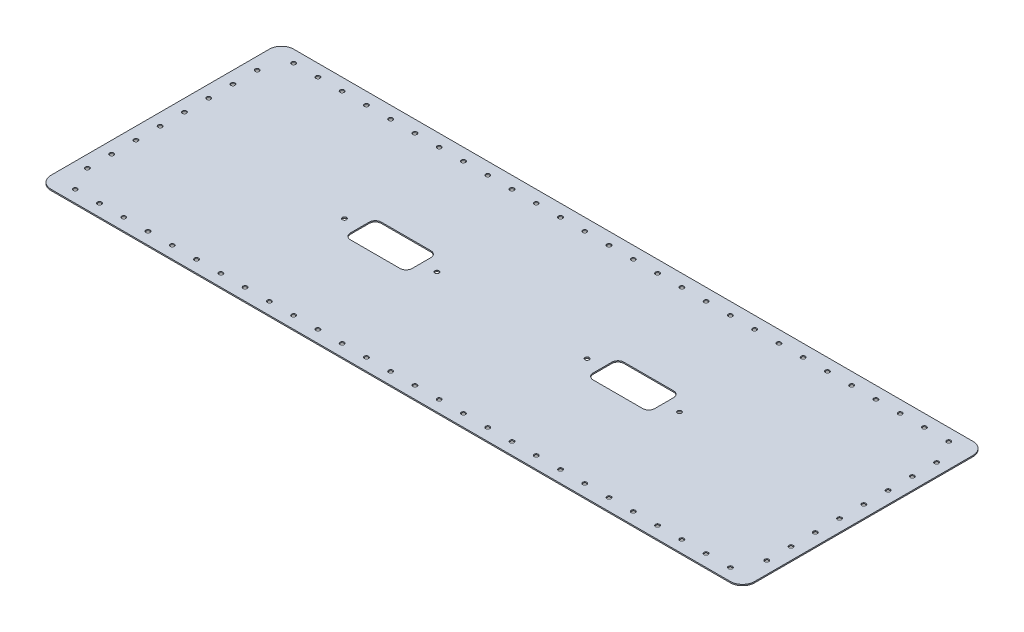
from build123d import *

# Parameters (mm, degrees)
SKETCH1_W                      = 580
SKETCH1_H                      = 200
BOSS_EXTRUDE1_DEPTH            = 1
FILLET1_R                      = 10
M3_CLEARANCE_HOLE1_AT_2_COUNT  = 2
M3_CLEARANCE_HOLE1_AT_2_PITCH  = 22.360679775
M3_CLEARANCE_HOLE1_AT_3_COUNT  = 2
M3_CLEARANCE_HOLE1_AT_3_PITCH  = 36.055512755
M3_CLEARANCE_HOLE1_AT_4_COUNT  = 2
M3_CLEARANCE_HOLE1_AT_4_PITCH  = 53.851648071
M3_CLEARANCE_HOLE1_AT_5_COUNT  = 2
M3_CLEARANCE_HOLE1_AT_5_PITCH  = 72.801098893
M3_CLEARANCE_HOLE1_AT_6_COUNT  = 2
M3_CLEARANCE_HOLE1_AT_6_PITCH  = 92.195444573
M3_CLEARANCE_HOLE1_AT_7_COUNT  = 2
M3_CLEARANCE_HOLE1_AT_7_PITCH  = 111.803398875
M3_CLEARANCE_HOLE1_AT_8_COUNT  = 2
M3_CLEARANCE_HOLE1_AT_8_PITCH  = 131.52946438
M3_CLEARANCE_HOLE1_AT_9_COUNT  = 2
M3_CLEARANCE_HOLE1_AT_9_PITCH  = 151.327459504
M3_CLEARANCE_HOLE1_AT_10_COUNT = 2
M3_CLEARANCE_HOLE1_AT_10_PITCH = 171.172427686
M3_CLEARANCE_HOLE1_AT_11_COUNT = 2
M3_CLEARANCE_HOLE1_AT_11_PITCH = 191.049731745
M3_CLEARANCE_HOLE1_AT_12_COUNT = 2
M3_CLEARANCE_HOLE1_AT_12_PITCH = 210.950231097
M3_CLEARANCE_HOLE1_AT_13_COUNT = 2
M3_CLEARANCE_HOLE1_AT_13_PITCH = 230.867927612
M3_CLEARANCE_HOLE1_AT_14_COUNT = 2
M3_CLEARANCE_HOLE1_AT_14_PITCH = 250.79872408
M3_CLEARANCE_HOLE1_AT_15_COUNT = 2
M3_CLEARANCE_HOLE1_AT_15_PITCH = 270.739727414
M3_CLEARANCE_HOLE1_AT_16_COUNT = 2
M3_CLEARANCE_HOLE1_AT_16_PITCH = 290.688837075
M3_CLEARANCE_HOLE1_AT_17_COUNT = 2
M3_CLEARANCE_HOLE1_AT_17_PITCH = 310.64449134
M3_CLEARANCE_HOLE1_AT_18_COUNT = 2
M3_CLEARANCE_HOLE1_AT_18_PITCH = 330.605505096
M3_CLEARANCE_HOLE1_AT_19_COUNT = 2
M3_CLEARANCE_HOLE1_AT_19_PITCH = 350.570962859
M3_CLEARANCE_HOLE1_AT_20_COUNT = 2
M3_CLEARANCE_HOLE1_AT_20_PITCH = 370.540146273
M3_CLEARANCE_HOLE1_AT_21_COUNT = 2
M3_CLEARANCE_HOLE1_AT_21_PITCH = 390.512483795
M3_CLEARANCE_HOLE1_AT_22_COUNT = 2
M3_CLEARANCE_HOLE1_AT_22_PITCH = 410.487515035
M3_CLEARANCE_HOLE1_AT_23_COUNT = 2
M3_CLEARANCE_HOLE1_AT_23_PITCH = 430.464865001
M3_CLEARANCE_HOLE1_AT_24_COUNT = 2
M3_CLEARANCE_HOLE1_AT_24_PITCH = 450.444225182
M3_CLEARANCE_HOLE1_AT_25_COUNT = 2
M3_CLEARANCE_HOLE1_AT_25_PITCH = 470.425339454
M3_CLEARANCE_HOLE1_AT_26_COUNT = 2
M3_CLEARANCE_HOLE1_AT_26_PITCH = 490.40799341
M3_CLEARANCE_HOLE1_AT_27_COUNT = 2
M3_CLEARANCE_HOLE1_AT_27_PITCH = 510.392006207
M3_CLEARANCE_HOLE1_AT_28_COUNT = 2
M3_CLEARANCE_HOLE1_AT_28_PITCH = 530.377224247
M3_CLEARANCE_HOLE1_AT_29_COUNT = 2
M3_CLEARANCE_HOLE1_AT_29_PITCH = 550.363516233
M3_CLEARANCE_HOLE1_AT_30_COUNT = 2
M3_CLEARANCE_HOLE1_AT_30_PITCH = 19.996953903
M3_CLEARANCE_HOLE1_AT_31_COUNT = 2
M3_CLEARANCE_HOLE1_AT_31_PITCH = 39.993907806
M3_CLEARANCE_HOLE1_AT_32_COUNT = 2
M3_CLEARANCE_HOLE1_AT_32_PITCH = 59.990861709
M3_CLEARANCE_HOLE1_AT_33_COUNT = 2
M3_CLEARANCE_HOLE1_AT_33_PITCH = 79.987815613
M3_CLEARANCE_HOLE1_AT_34_COUNT = 2
M3_CLEARANCE_HOLE1_AT_34_PITCH = 99.984769516
M3_CLEARANCE_HOLE1_AT_35_COUNT = 2
M3_CLEARANCE_HOLE1_AT_35_PITCH = 119.981723419
M3_CLEARANCE_HOLE1_AT_36_COUNT = 2
M3_CLEARANCE_HOLE1_AT_36_PITCH = 139.978677322
M3_CLEARANCE_HOLE1_AT_37_COUNT = 2
M3_CLEARANCE_HOLE1_AT_37_PITCH = 160.312195419
M3_CLEARANCE_HOLE1_AT_38_COUNT = 2
M3_CLEARANCE_HOLE1_AT_38_PITCH = 162.788205961
M3_CLEARANCE_HOLE1_AT_39_COUNT = 2
M3_CLEARANCE_HOLE1_AT_39_PITCH = 167.630546142
M3_CLEARANCE_HOLE1_AT_40_COUNT = 2
M3_CLEARANCE_HOLE1_AT_40_PITCH = 174.642491966
M3_CLEARANCE_HOLE1_AT_41_COUNT = 2
M3_CLEARANCE_HOLE1_AT_41_PITCH = 183.575597507
M3_CLEARANCE_HOLE1_AT_42_COUNT = 2
M3_CLEARANCE_HOLE1_AT_42_PITCH = 194.164878389
M3_CLEARANCE_HOLE1_AT_43_COUNT = 2
M3_CLEARANCE_HOLE1_AT_43_PITCH = 206.155281281
M3_CLEARANCE_HOLE1_AT_44_COUNT = 2
M3_CLEARANCE_HOLE1_AT_44_PITCH = 219.317121995
M3_CLEARANCE_HOLE1_AT_45_COUNT = 2
M3_CLEARANCE_HOLE1_AT_45_PITCH = 233.452350599
M3_CLEARANCE_HOLE1_AT_46_COUNT = 2
M3_CLEARANCE_HOLE1_AT_46_PITCH = 248.394846967
M3_CLEARANCE_HOLE1_AT_47_COUNT = 2
M3_CLEARANCE_HOLE1_AT_47_PITCH = 264.007575649
M3_CLEARANCE_HOLE1_AT_48_COUNT = 2
M3_CLEARANCE_HOLE1_AT_48_PITCH = 280.178514522
M3_CLEARANCE_HOLE1_AT_49_COUNT = 2
M3_CLEARANCE_HOLE1_AT_49_PITCH = 296.816441593
M3_CLEARANCE_HOLE1_AT_50_COUNT = 2
M3_CLEARANCE_HOLE1_AT_50_PITCH = 313.84709653
M3_CLEARANCE_HOLE1_AT_51_COUNT = 2
M3_CLEARANCE_HOLE1_AT_51_PITCH = 331.209903234
M3_CLEARANCE_HOLE1_AT_52_COUNT = 2
M3_CLEARANCE_HOLE1_AT_52_PITCH = 348.85527085
M3_CLEARANCE_HOLE1_AT_53_COUNT = 2
M3_CLEARANCE_HOLE1_AT_53_PITCH = 366.742416418
M3_CLEARANCE_HOLE1_AT_54_COUNT = 2
M3_CLEARANCE_HOLE1_AT_54_PITCH = 384.837628098
M3_CLEARANCE_HOLE1_AT_55_COUNT = 2
M3_CLEARANCE_HOLE1_AT_55_PITCH = 403.112887415
M3_CLEARANCE_HOLE1_AT_56_COUNT = 2
M3_CLEARANCE_HOLE1_AT_56_PITCH = 421.544778167
M3_CLEARANCE_HOLE1_AT_57_COUNT = 2
M3_CLEARANCE_HOLE1_AT_57_PITCH = 440.113621693
M3_CLEARANCE_HOLE1_AT_58_COUNT = 2
M3_CLEARANCE_HOLE1_AT_58_PITCH = 458.802789878
M3_CLEARANCE_HOLE1_AT_59_COUNT = 2
M3_CLEARANCE_HOLE1_AT_59_PITCH = 477.59815745
M3_CLEARANCE_HOLE1_AT_60_COUNT = 2
M3_CLEARANCE_HOLE1_AT_60_PITCH = 496.487663492
M3_CLEARANCE_HOLE1_AT_61_COUNT = 2
M3_CLEARANCE_HOLE1_AT_61_PITCH = 515.460958754
M3_CLEARANCE_HOLE1_AT_62_COUNT = 2
M3_CLEARANCE_HOLE1_AT_62_PITCH = 534.509120596
M3_CLEARANCE_HOLE1_AT_63_COUNT = 2
M3_CLEARANCE_HOLE1_AT_63_PITCH = 553.624421427
M3_CLEARANCE_HOLE1_AT_64_COUNT = 2
M3_CLEARANCE_HOLE1_AT_64_PITCH = 572.800139665
M3_CLEARANCE_HOLE1_AT_65_COUNT = 2
M3_CLEARANCE_HOLE1_AT_65_PITCH = 560
M3_CLEARANCE_HOLE1_AT_66_COUNT = 2
M3_CLEARANCE_HOLE1_AT_66_PITCH = 560.356920333
M3_CLEARANCE_HOLE1_AT_67_COUNT = 2
M3_CLEARANCE_HOLE1_AT_67_PITCH = 561.426319887
M3_CLEARANCE_HOLE1_AT_68_COUNT = 2
M3_CLEARANCE_HOLE1_AT_68_PITCH = 563.204140156
M3_CLEARANCE_HOLE1_AT_69_COUNT = 2
M3_CLEARANCE_HOLE1_AT_69_PITCH = 565.683701945
M3_CLEARANCE_HOLE1_AT_70_COUNT = 2
M3_CLEARANCE_HOLE1_AT_70_PITCH = 568.855828954
M3_CLEARANCE_HOLE1_AT_71_COUNT = 2
M3_CLEARANCE_HOLE1_AT_71_PITCH = 572.709013334
M3_CLEARANCE_HOLE1_AT_72_COUNT = 2
M3_CLEARANCE_HOLE1_AT_72_PITCH = 577.229616448
SKETCH4_W                      = 50.8
SKETCH4_H                      = 25.4
CUT_EXTRUDE1_DEPTH             = 10
FILLET2_R                      = 5
M3_CLEARANCE_HOLE4_AT_2_COUNT  = 2
M3_CLEARANCE_HOLE4_AT_2_PITCH  = 76.2
M3_CLEARANCE_HOLE4_AT_3_COUNT  = 2
M3_CLEARANCE_HOLE4_AT_3_PITCH  = 123.8
M3_CLEARANCE_HOLE4_AT_4_COUNT  = 2
M3_CLEARANCE_HOLE4_AT_4_PITCH  = 200


with BuildPart() as part:
    # Sketch1 → Boss-Extrude1 (new body)
    with BuildSketch(Plane(origin=(0, 0, 0), x_dir=(1, 0, 0), z_dir=(0, 1, 0))):
        Rectangle(SKETCH1_W, SKETCH1_H)
    extrude(amount=BOSS_EXTRUDE1_DEPTH)

    # Fillet1
    fillet1_edges = [part.edges().sort_by_distance(p)[0] for p in [
        (290, 0.5, 100),
        (-290, 0.5, 100),
        (-290, 0.5, -100),
        (290, 0.5, -100),
    ]]
    fillet(fillet1_edges, radius=FILLET1_R)

    # Sketch3 → M3 Clearance Hole1 (revolve, cut)
    with BuildSketch(Plane(origin=(280, 1, -70), x_dir=(0, 0, 1), z_dir=(1, 0, 0))):
        Polygon((0, 0), (0, 1), (1.7, 1), (1.7, 0.025), (1.725, 0), align=None)
    m3_clearance_hole1 = revolve(axis=Axis((280, 7.35, -70), (0, -1, 0)), mode=Mode.SUBTRACT)

    # M3 Clearance Hole1 at 2: M3 Clearance Hole1 ×2
    with Locations(*[Vector(-0.447213595, 0, -0.894427191) * (i * M3_CLEARANCE_HOLE1_AT_2_PITCH) for i in range(1, M3_CLEARANCE_HOLE1_AT_2_COUNT)]):
        add(m3_clearance_hole1, mode=Mode.SUBTRACT)

    # M3 Clearance Hole1 at 3: M3 Clearance Hole1 ×2
    with Locations(*[Vector(-0.832050294, 0, -0.554700196) * (i * M3_CLEARANCE_HOLE1_AT_3_PITCH) for i in range(1, M3_CLEARANCE_HOLE1_AT_3_COUNT)]):
        add(m3_clearance_hole1, mode=Mode.SUBTRACT)

    # M3 Clearance Hole1 at 4: M3 Clearance Hole1 ×2
    with Locations(*[Vector(-0.928476691, 0, -0.371390676) * (i * M3_CLEARANCE_HOLE1_AT_4_PITCH) for i in range(1, M3_CLEARANCE_HOLE1_AT_4_COUNT)]):
        add(m3_clearance_hole1, mode=Mode.SUBTRACT)

    # M3 Clearance Hole1 at 5: M3 Clearance Hole1 ×2
    with Locations(*[Vector(-0.961523948, 0, -0.274721128) * (i * M3_CLEARANCE_HOLE1_AT_5_PITCH) for i in range(1, M3_CLEARANCE_HOLE1_AT_5_COUNT)]):
        add(m3_clearance_hole1, mode=Mode.SUBTRACT)

    # M3 Clearance Hole1 at 6: M3 Clearance Hole1 ×2
    with Locations(*[Vector(-0.97618706, 0, -0.216930458) * (i * M3_CLEARANCE_HOLE1_AT_6_PITCH) for i in range(1, M3_CLEARANCE_HOLE1_AT_6_COUNT)]):
        add(m3_clearance_hole1, mode=Mode.SUBTRACT)

    # M3 Clearance Hole1 at 7: M3 Clearance Hole1 ×2
    with Locations(*[Vector(-0.98386991, 0, -0.178885438) * (i * M3_CLEARANCE_HOLE1_AT_7_PITCH) for i in range(1, M3_CLEARANCE_HOLE1_AT_7_COUNT)]):
        add(m3_clearance_hole1, mode=Mode.SUBTRACT)

    # M3 Clearance Hole1 at 8: M3 Clearance Hole1 ×2
    with Locations(*[Vector(-0.988371698, 0, -0.152057184) * (i * M3_CLEARANCE_HOLE1_AT_8_PITCH) for i in range(1, M3_CLEARANCE_HOLE1_AT_8_COUNT)]):
        add(m3_clearance_hole1, mode=Mode.SUBTRACT)

    # M3 Clearance Hole1 at 9: M3 Clearance Hole1 ×2
    with Locations(*[Vector(-0.991227901, 0, -0.13216372) * (i * M3_CLEARANCE_HOLE1_AT_9_PITCH) for i in range(1, M3_CLEARANCE_HOLE1_AT_9_COUNT)]):
        add(m3_clearance_hole1, mode=Mode.SUBTRACT)

    # M3 Clearance Hole1 at 10: M3 Clearance Hole1 ×2
    with Locations(*[Vector(-0.993150604, 0, -0.116841248) * (i * M3_CLEARANCE_HOLE1_AT_10_PITCH) for i in range(1, M3_CLEARANCE_HOLE1_AT_10_COUNT)]):
        add(m3_clearance_hole1, mode=Mode.SUBTRACT)

    # M3 Clearance Hole1 at 11: M3 Clearance Hole1 ×2
    with Locations(*[Vector(-0.994505453, 0, -0.104684785) * (i * M3_CLEARANCE_HOLE1_AT_11_PITCH) for i in range(1, M3_CLEARANCE_HOLE1_AT_11_COUNT)]):
        add(m3_clearance_hole1, mode=Mode.SUBTRACT)

    # M3 Clearance Hole1 at 12: M3 Clearance Hole1 ×2
    with Locations(*[Vector(-0.995495473, 0, -0.094809093) * (i * M3_CLEARANCE_HOLE1_AT_12_PITCH) for i in range(1, M3_CLEARANCE_HOLE1_AT_12_COUNT)]):
        add(m3_clearance_hole1, mode=Mode.SUBTRACT)

    # M3 Clearance Hole1 at 13: M3 Clearance Hole1 ×2
    with Locations(*[Vector(-0.996240588, 0, -0.086629616) * (i * M3_CLEARANCE_HOLE1_AT_13_PITCH) for i in range(1, M3_CLEARANCE_HOLE1_AT_13_COUNT)]):
        add(m3_clearance_hole1, mode=Mode.SUBTRACT)

    # M3 Clearance Hole1 at 14: M3 Clearance Hole1 ×2
    with Locations(*[Vector(-0.996815279, 0, -0.079745222) * (i * M3_CLEARANCE_HOLE1_AT_14_PITCH) for i in range(1, M3_CLEARANCE_HOLE1_AT_14_COUNT)]):
        add(m3_clearance_hole1, mode=Mode.SUBTRACT)

    # M3 Clearance Hole1 at 15: M3 Clearance Hole1 ×2
    with Locations(*[Vector(-0.997267754, 0, -0.073871686) * (i * M3_CLEARANCE_HOLE1_AT_15_PITCH) for i in range(1, M3_CLEARANCE_HOLE1_AT_15_COUNT)]):
        add(m3_clearance_hole1, mode=Mode.SUBTRACT)

    # M3 Clearance Hole1 at 16: M3 Clearance Hole1 ×2
    with Locations(*[Vector(-0.997630328, 0, -0.068802092) * (i * M3_CLEARANCE_HOLE1_AT_16_PITCH) for i in range(1, M3_CLEARANCE_HOLE1_AT_16_COUNT)]):
        add(m3_clearance_hole1, mode=Mode.SUBTRACT)

    # M3 Clearance Hole1 at 17: M3 Clearance Hole1 ×2
    with Locations(*[Vector(-0.997925309, 0, -0.064382278) * (i * M3_CLEARANCE_HOLE1_AT_17_PITCH) for i in range(1, M3_CLEARANCE_HOLE1_AT_17_COUNT)]):
        add(m3_clearance_hole1, mode=Mode.SUBTRACT)

    # M3 Clearance Hole1 at 18: M3 Clearance Hole1 ×2
    with Locations(*[Vector(-0.998168497, 0, -0.06049506) * (i * M3_CLEARANCE_HOLE1_AT_18_PITCH) for i in range(1, M3_CLEARANCE_HOLE1_AT_18_COUNT)]):
        add(m3_clearance_hole1, mode=Mode.SUBTRACT)

    # M3 Clearance Hole1 at 19: M3 Clearance Hole1 ×2
    with Locations(*[Vector(-0.998371334, 0, -0.057049791) * (i * M3_CLEARANCE_HOLE1_AT_19_PITCH) for i in range(1, M3_CLEARANCE_HOLE1_AT_19_COUNT)]):
        add(m3_clearance_hole1, mode=Mode.SUBTRACT)

    # M3 Clearance Hole1 at 20: M3 Clearance Hole1 ×2
    with Locations(*[Vector(-0.998542273, 0, -0.053975258) * (i * M3_CLEARANCE_HOLE1_AT_20_PITCH) for i in range(1, M3_CLEARANCE_HOLE1_AT_20_COUNT)]):
        add(m3_clearance_hole1, mode=Mode.SUBTRACT)

    # M3 Clearance Hole1 at 21: M3 Clearance Hole1 ×2
    with Locations(*[Vector(-0.998687663, 0, -0.051214752) * (i * M3_CLEARANCE_HOLE1_AT_21_PITCH) for i in range(1, M3_CLEARANCE_HOLE1_AT_21_COUNT)]):
        add(m3_clearance_hole1, mode=Mode.SUBTRACT)

    # M3 Clearance Hole1 at 22: M3 Clearance Hole1 ×2
    with Locations(*[Vector(-0.998812351, 0, -0.048722554) * (i * M3_CLEARANCE_HOLE1_AT_22_PITCH) for i in range(1, M3_CLEARANCE_HOLE1_AT_22_COUNT)]):
        add(m3_clearance_hole1, mode=Mode.SUBTRACT)

    # M3 Clearance Hole1 at 23: M3 Clearance Hole1 ×2
    with Locations(*[Vector(-0.998920086, 0, -0.046461399) * (i * M3_CLEARANCE_HOLE1_AT_23_PITCH) for i in range(1, M3_CLEARANCE_HOLE1_AT_23_COUNT)]):
        add(m3_clearance_hole1, mode=Mode.SUBTRACT)

    # M3 Clearance Hole1 at 24: M3 Clearance Hole1 ×2
    with Locations(*[Vector(-0.999013806, 0, -0.044400614) * (i * M3_CLEARANCE_HOLE1_AT_24_PITCH) for i in range(1, M3_CLEARANCE_HOLE1_AT_24_COUNT)]):
        add(m3_clearance_hole1, mode=Mode.SUBTRACT)

    # M3 Clearance Hole1 at 25: M3 Clearance Hole1 ×2
    with Locations(*[Vector(-0.999095841, 0, -0.042514717) * (i * M3_CLEARANCE_HOLE1_AT_25_PITCH) for i in range(1, M3_CLEARANCE_HOLE1_AT_25_COUNT)]):
        add(m3_clearance_hole1, mode=Mode.SUBTRACT)

    # M3 Clearance Hole1 at 26: M3 Clearance Hole1 ×2
    with Locations(*[Vector(-0.999168053, 0, -0.04078237) * (i * M3_CLEARANCE_HOLE1_AT_26_PITCH) for i in range(1, M3_CLEARANCE_HOLE1_AT_26_COUNT)]):
        add(m3_clearance_hole1, mode=Mode.SUBTRACT)

    # M3 Clearance Hole1 at 27: M3 Clearance Hole1 ×2
    with Locations(*[Vector(-0.999231951, 0, -0.039185567) * (i * M3_CLEARANCE_HOLE1_AT_27_PITCH) for i in range(1, M3_CLEARANCE_HOLE1_AT_27_COUNT)]):
        add(m3_clearance_hole1, mode=Mode.SUBTRACT)

    # M3 Clearance Hole1 at 28: M3 Clearance Hole1 ×2
    with Locations(*[Vector(-0.999288762, 0, -0.03770901) * (i * M3_CLEARANCE_HOLE1_AT_28_PITCH) for i in range(1, M3_CLEARANCE_HOLE1_AT_28_COUNT)]):
        add(m3_clearance_hole1, mode=Mode.SUBTRACT)

    # M3 Clearance Hole1 at 29: M3 Clearance Hole1 ×2
    with Locations(*[Vector(-0.999339498, 0, -0.036339618) * (i * M3_CLEARANCE_HOLE1_AT_29_PITCH) for i in range(1, M3_CLEARANCE_HOLE1_AT_29_COUNT)]):
        add(m3_clearance_hole1, mode=Mode.SUBTRACT)

    # M3 Clearance Hole1 at 30: M3 Clearance Hole1 ×2
    with Locations(*[(0, 0, i * M3_CLEARANCE_HOLE1_AT_30_PITCH) for i in range(1, M3_CLEARANCE_HOLE1_AT_30_COUNT)]):
        add(m3_clearance_hole1, mode=Mode.SUBTRACT)

    # M3 Clearance Hole1 at 31: M3 Clearance Hole1 ×2
    with Locations(*[(0, 0, i * M3_CLEARANCE_HOLE1_AT_31_PITCH) for i in range(1, M3_CLEARANCE_HOLE1_AT_31_COUNT)]):
        add(m3_clearance_hole1, mode=Mode.SUBTRACT)

    # M3 Clearance Hole1 at 32: M3 Clearance Hole1 ×2
    with Locations(*[(0, 0, i * M3_CLEARANCE_HOLE1_AT_32_PITCH) for i in range(1, M3_CLEARANCE_HOLE1_AT_32_COUNT)]):
        add(m3_clearance_hole1, mode=Mode.SUBTRACT)

    # M3 Clearance Hole1 at 33: M3 Clearance Hole1 ×2
    with Locations(*[(0, 0, i * M3_CLEARANCE_HOLE1_AT_33_PITCH) for i in range(1, M3_CLEARANCE_HOLE1_AT_33_COUNT)]):
        add(m3_clearance_hole1, mode=Mode.SUBTRACT)

    # M3 Clearance Hole1 at 34: M3 Clearance Hole1 ×2
    with Locations(*[(0, 0, i * M3_CLEARANCE_HOLE1_AT_34_PITCH) for i in range(1, M3_CLEARANCE_HOLE1_AT_34_COUNT)]):
        add(m3_clearance_hole1, mode=Mode.SUBTRACT)

    # M3 Clearance Hole1 at 35: M3 Clearance Hole1 ×2
    with Locations(*[(0, 0, i * M3_CLEARANCE_HOLE1_AT_35_PITCH) for i in range(1, M3_CLEARANCE_HOLE1_AT_35_COUNT)]):
        add(m3_clearance_hole1, mode=Mode.SUBTRACT)

    # M3 Clearance Hole1 at 36: M3 Clearance Hole1 ×2
    with Locations(*[(0, 0, i * M3_CLEARANCE_HOLE1_AT_36_PITCH) for i in range(1, M3_CLEARANCE_HOLE1_AT_36_COUNT)]):
        add(m3_clearance_hole1, mode=Mode.SUBTRACT)

    # M3 Clearance Hole1 at 37: M3 Clearance Hole1 ×2
    with Locations(*[Vector(-0.062378286, 0, 0.998052578) * (i * M3_CLEARANCE_HOLE1_AT_37_PITCH) for i in range(1, M3_CLEARANCE_HOLE1_AT_37_COUNT)]):
        add(m3_clearance_hole1, mode=Mode.SUBTRACT)

    # M3 Clearance Hole1 at 38: M3 Clearance Hole1 ×2
    with Locations(*[Vector(-0.184288535, 0, 0.982872187) * (i * M3_CLEARANCE_HOLE1_AT_38_PITCH) for i in range(1, M3_CLEARANCE_HOLE1_AT_38_COUNT)]):
        add(m3_clearance_hole1, mode=Mode.SUBTRACT)

    # M3 Clearance Hole1 at 39: M3 Clearance Hole1 ×2
    with Locations(*[Vector(-0.298274993, 0, 0.954479978) * (i * M3_CLEARANCE_HOLE1_AT_39_PITCH) for i in range(1, M3_CLEARANCE_HOLE1_AT_39_COUNT)]):
        add(m3_clearance_hole1, mode=Mode.SUBTRACT)

    # M3 Clearance Hole1 at 40: M3 Clearance Hole1 ×2
    with Locations(*[Vector(-0.400818834, 0, 0.916157335) * (i * M3_CLEARANCE_HOLE1_AT_40_PITCH) for i in range(1, M3_CLEARANCE_HOLE1_AT_40_COUNT)]):
        add(m3_clearance_hole1, mode=Mode.SUBTRACT)

    # M3 Clearance Hole1 at 41: M3 Clearance Hole1 ×2
    with Locations(*[Vector(-0.49026124, 0, 0.871575537) * (i * M3_CLEARANCE_HOLE1_AT_41_PITCH) for i in range(1, M3_CLEARANCE_HOLE1_AT_41_COUNT)]):
        add(m3_clearance_hole1, mode=Mode.SUBTRACT)

    # M3 Clearance Hole1 at 42: M3 Clearance Hole1 ×2
    with Locations(*[Vector(-0.566528823, 0, 0.824041924) * (i * M3_CLEARANCE_HOLE1_AT_42_PITCH) for i in range(1, M3_CLEARANCE_HOLE1_AT_42_COUNT)]):
        add(m3_clearance_hole1, mode=Mode.SUBTRACT)

    # M3 Clearance Hole1 at 43: M3 Clearance Hole1 ×2
    with Locations(*[Vector(-0.630592625, 0, 0.776114) * (i * M3_CLEARANCE_HOLE1_AT_43_PITCH) for i in range(1, M3_CLEARANCE_HOLE1_AT_43_COUNT)]):
        add(m3_clearance_hole1, mode=Mode.SUBTRACT)

    # M3 Clearance Hole1 at 44: M3 Clearance Hole1 ×2
    with Locations(*[Vector(-0.683941129, 0, 0.729537204) * (i * M3_CLEARANCE_HOLE1_AT_44_PITCH) for i in range(1, M3_CLEARANCE_HOLE1_AT_44_COUNT)]):
        add(m3_clearance_hole1, mode=Mode.SUBTRACT)

    # M3 Clearance Hole1 at 45: M3 Clearance Hole1 ×2
    with Locations(*[Vector(-0.728199993, 0, 0.685364699) * (i * M3_CLEARANCE_HOLE1_AT_45_PITCH) for i in range(1, M3_CLEARANCE_HOLE1_AT_45_COUNT)]):
        add(m3_clearance_hole1, mode=Mode.SUBTRACT)

    # M3 Clearance Hole1 at 46: M3 Clearance Hole1 ×2
    with Locations(*[Vector(-0.764911198, 0, 0.644135746) * (i * M3_CLEARANCE_HOLE1_AT_46_PITCH) for i in range(1, M3_CLEARANCE_HOLE1_AT_46_COUNT)]):
        add(m3_clearance_hole1, mode=Mode.SUBTRACT)

    # M3 Clearance Hole1 at 47: M3 Clearance Hole1 ×2
    with Locations(*[Vector(-0.79543172, 0, 0.606043215) * (i * M3_CLEARANCE_HOLE1_AT_47_PITCH) for i in range(1, M3_CLEARANCE_HOLE1_AT_47_COUNT)]):
        add(m3_clearance_hole1, mode=Mode.SUBTRACT)

    # M3 Clearance Hole1 at 48: M3 Clearance Hole1 ×2
    with Locations(*[Vector(-0.820905202, 0, 0.571064488) * (i * M3_CLEARANCE_HOLE1_AT_48_PITCH) for i in range(1, M3_CLEARANCE_HOLE1_AT_48_COUNT)]):
        add(m3_clearance_hole1, mode=Mode.SUBTRACT)

    # M3 Clearance Hole1 at 49: M3 Clearance Hole1 ×2
    with Locations(*[Vector(-0.842271401, 0, 0.539053696) * (i * M3_CLEARANCE_HOLE1_AT_49_PITCH) for i in range(1, M3_CLEARANCE_HOLE1_AT_49_COUNT)]):
        add(m3_clearance_hole1, mode=Mode.SUBTRACT)

    # M3 Clearance Hole1 at 50: M3 Clearance Hole1 ×2
    with Locations(*[Vector(-0.860291534, 0, 0.50980239) * (i * M3_CLEARANCE_HOLE1_AT_50_PITCH) for i in range(1, M3_CLEARANCE_HOLE1_AT_50_COUNT)]):
        add(m3_clearance_hole1, mode=Mode.SUBTRACT)

    # M3 Clearance Hole1 at 51: M3 Clearance Hole1 ×2
    with Locations(*[Vector(-0.875577684, 0, 0.483077343) * (i * M3_CLEARANCE_HOLE1_AT_51_PITCH) for i in range(1, M3_CLEARANCE_HOLE1_AT_51_COUNT)]):
        add(m3_clearance_hole1, mode=Mode.SUBTRACT)

    # M3 Clearance Hole1 at 52: M3 Clearance Hole1 ×2
    with Locations(*[Vector(-0.888620657, 0, 0.45864292) * (i * M3_CLEARANCE_HOLE1_AT_52_PITCH) for i in range(1, M3_CLEARANCE_HOLE1_AT_52_COUNT)]):
        add(m3_clearance_hole1, mode=Mode.SUBTRACT)

    # M3 Clearance Hole1 at 53: M3 Clearance Hole1 ×2
    with Locations(*[Vector(-0.899814107, 0, 0.436273507) * (i * M3_CLEARANCE_HOLE1_AT_53_PITCH) for i in range(1, M3_CLEARANCE_HOLE1_AT_53_COUNT)]):
        add(m3_clearance_hole1, mode=Mode.SUBTRACT)

    # M3 Clearance Hole1 at 54: M3 Clearance Hole1 ×2
    with Locations(*[Vector(-0.909474476, 0, 0.41575976) * (i * M3_CLEARANCE_HOLE1_AT_54_PITCH) for i in range(1, M3_CLEARANCE_HOLE1_AT_54_COUNT)]):
        add(m3_clearance_hole1, mode=Mode.SUBTRACT)

    # M3 Clearance Hole1 at 55: M3 Clearance Hole1 ×2
    with Locations(*[Vector(-0.917857036, 0, 0.396911151) * (i * M3_CLEARANCE_HOLE1_AT_55_PITCH) for i in range(1, M3_CLEARANCE_HOLE1_AT_55_COUNT)]):
        add(m3_clearance_hole1, mode=Mode.SUBTRACT)

    # M3 Clearance Hole1 at 56: M3 Clearance Hole1 ×2
    with Locations(*[Vector(-0.925168618, 0, 0.379556356) * (i * M3_CLEARANCE_HOLE1_AT_56_PITCH) for i in range(1, M3_CLEARANCE_HOLE1_AT_56_COUNT)]):
        add(m3_clearance_hole1, mode=Mode.SUBTRACT)

    # M3 Clearance Hole1 at 57: M3 Clearance Hole1 ×2
    with Locations(*[Vector(-0.931577619, 0, 0.363542486) * (i * M3_CLEARANCE_HOLE1_AT_57_PITCH) for i in range(1, M3_CLEARANCE_HOLE1_AT_57_COUNT)]):
        add(m3_clearance_hole1, mode=Mode.SUBTRACT)

    # M3 Clearance Hole1 at 58: M3 Clearance Hole1 ×2
    with Locations(*[Vector(-0.937221851, 0, 0.348733712) * (i * M3_CLEARANCE_HOLE1_AT_58_PITCH) for i in range(1, M3_CLEARANCE_HOLE1_AT_58_COUNT)]):
        add(m3_clearance_hole1, mode=Mode.SUBTRACT)

    # M3 Clearance Hole1 at 59: M3 Clearance Hole1 ×2
    with Locations(*[Vector(-0.94221469, 0, 0.335009668) * (i * M3_CLEARANCE_HOLE1_AT_59_PITCH) for i in range(1, M3_CLEARANCE_HOLE1_AT_59_COUNT)]):
        add(m3_clearance_hole1, mode=Mode.SUBTRACT)

    # M3 Clearance Hole1 at 60: M3 Clearance Hole1 ×2
    with Locations(*[Vector(-0.946649906, 0, 0.322263798) * (i * M3_CLEARANCE_HOLE1_AT_60_PITCH) for i in range(1, M3_CLEARANCE_HOLE1_AT_60_COUNT)]):
        add(m3_clearance_hole1, mode=Mode.SUBTRACT)

    # M3 Clearance Hole1 at 61: M3 Clearance Hole1 ×2
    with Locations(*[Vector(-0.950605456, 0, 0.310401782) * (i * M3_CLEARANCE_HOLE1_AT_61_PITCH) for i in range(1, M3_CLEARANCE_HOLE1_AT_61_COUNT)]):
        add(m3_clearance_hole1, mode=Mode.SUBTRACT)

    # M3 Clearance Hole1 at 62: M3 Clearance Hole1 ×2
    with Locations(*[Vector(-0.954146488, 0, 0.299340075) * (i * M3_CLEARANCE_HOLE1_AT_62_PITCH) for i in range(1, M3_CLEARANCE_HOLE1_AT_62_COUNT)]):
        add(m3_clearance_hole1, mode=Mode.SUBTRACT)

    # M3 Clearance Hole1 at 63: M3 Clearance Hole1 ×2
    with Locations(*[Vector(-0.957327711, 0, 0.289004592) * (i * M3_CLEARANCE_HOLE1_AT_63_PITCH) for i in range(1, M3_CLEARANCE_HOLE1_AT_63_COUNT)]):
        add(m3_clearance_hole1, mode=Mode.SUBTRACT)

    # M3 Clearance Hole1 at 64: M3 Clearance Hole1 ×2
    with Locations(*[Vector(-0.960195297, 0, 0.279329541) * (i * M3_CLEARANCE_HOLE1_AT_64_PITCH) for i in range(1, M3_CLEARANCE_HOLE1_AT_64_COUNT)]):
        add(m3_clearance_hole1, mode=Mode.SUBTRACT)

    # M3 Clearance Hole1 at 65: M3 Clearance Hole1 ×2
    with Locations(*[(-i * M3_CLEARANCE_HOLE1_AT_65_PITCH, 0, 0) for i in range(1, M3_CLEARANCE_HOLE1_AT_65_COUNT)]):
        add(m3_clearance_hole1, mode=Mode.SUBTRACT)

    # M3 Clearance Hole1 at 66: M3 Clearance Hole1 ×2
    with Locations(*[Vector(-0.999363048, 0, 0.035686101) * (i * M3_CLEARANCE_HOLE1_AT_66_PITCH) for i in range(1, M3_CLEARANCE_HOLE1_AT_66_COUNT)]):
        add(m3_clearance_hole1, mode=Mode.SUBTRACT)

    # M3 Clearance Hole1 at 67: M3 Clearance Hole1 ×2
    with Locations(*[Vector(-0.997459471, 0, 0.071236254) * (i * M3_CLEARANCE_HOLE1_AT_67_PITCH) for i in range(1, M3_CLEARANCE_HOLE1_AT_67_COUNT)]):
        add(m3_clearance_hole1, mode=Mode.SUBTRACT)

    # M3 Clearance Hole1 at 68: M3 Clearance Hole1 ×2
    with Locations(*[Vector(-0.994310873, 0, 0.106517082) * (i * M3_CLEARANCE_HOLE1_AT_68_PITCH) for i in range(1, M3_CLEARANCE_HOLE1_AT_68_COUNT)]):
        add(m3_clearance_hole1, mode=Mode.SUBTRACT)

    # M3 Clearance Hole1 at 69: M3 Clearance Hole1 ×2
    with Locations(*[Vector(-0.989952509, 0, 0.141400248) * (i * M3_CLEARANCE_HOLE1_AT_69_PITCH) for i in range(1, M3_CLEARANCE_HOLE1_AT_69_COUNT)]):
        add(m3_clearance_hole1, mode=Mode.SUBTRACT)

    # M3 Clearance Hole1 at 70: M3 Clearance Hole1 ×2
    with Locations(*[Vector(-0.984432208, 0, 0.175764692) * (i * M3_CLEARANCE_HOLE1_AT_70_PITCH) for i in range(1, M3_CLEARANCE_HOLE1_AT_70_COUNT)]):
        add(m3_clearance_hole1, mode=Mode.SUBTRACT)

    # M3 Clearance Hole1 at 71: M3 Clearance Hole1 ×2
    with Locations(*[Vector(-0.977808952, 0, 0.209498577) * (i * M3_CLEARANCE_HOLE1_AT_71_PITCH) for i in range(1, M3_CLEARANCE_HOLE1_AT_71_COUNT)]):
        add(m3_clearance_hole1, mode=Mode.SUBTRACT)

    # M3 Clearance Hole1 at 72: M3 Clearance Hole1 ×2
    with Locations(*[Vector(-0.970151191, 0, 0.242500858) * (i * M3_CLEARANCE_HOLE1_AT_72_PITCH) for i in range(1, M3_CLEARANCE_HOLE1_AT_72_COUNT)]):
        add(m3_clearance_hole1, mode=Mode.SUBTRACT)

    # Sketch4 → Cut-Extrude1 (cut)
    with BuildSketch(Plane(origin=(0, 1, 0), x_dir=(1, 0, 0), z_dir=(0, 1, 0))):
        with Locations((-100, 0)):
            Rectangle(SKETCH4_W, SKETCH4_H)
        with Locations((100, 0)):
            Rectangle(SKETCH4_W, SKETCH4_H)
    extrude(amount=-CUT_EXTRUDE1_DEPTH, mode=Mode.SUBTRACT)

    # Fillet2
    fillet2_edges = [part.edges().sort_by_distance(p)[0] for p in [
        (-74.6, 0.5, -12.7),
        (-74.6, 0.5, 12.7),
        (-125.4, 0.5, 12.7),
        (-125.4, 0.5, -12.7),
        (74.6, 0.5, -12.7),
        (125.4, 0.5, -12.7),
        (125.4, 0.5, 12.7),
        (74.6, 0.5, 12.7),
    ]]
    fillet(fillet2_edges, radius=FILLET2_R)

    # Sketch6 → M3 Clearance Hole4 (revolve, cut)
    with BuildSketch(Plane(origin=(-61.9, 1, 0), x_dir=(0, 0, 1), z_dir=(1, 0, 0))):
        Polygon((0, 0), (0, 1), (1.7, 1), (1.7, 0.025), (1.725, 0), align=None)
    m3_clearance_hole4 = revolve(axis=Axis((-61.9, 7.35, 0), (0, -1, 0)), mode=Mode.SUBTRACT)

    # M3 Clearance Hole4 at 2: M3 Clearance Hole4 ×2
    with Locations(*[(-i * M3_CLEARANCE_HOLE4_AT_2_PITCH, 0, 0) for i in range(1, M3_CLEARANCE_HOLE4_AT_2_COUNT)]):
        add(m3_clearance_hole4, mode=Mode.SUBTRACT)

    # M3 Clearance Hole4 at 3: M3 Clearance Hole4 ×2
    with Locations(*[(i * M3_CLEARANCE_HOLE4_AT_3_PITCH, 0, 0) for i in range(1, M3_CLEARANCE_HOLE4_AT_3_COUNT)]):
        add(m3_clearance_hole4, mode=Mode.SUBTRACT)

    # M3 Clearance Hole4 at 4: M3 Clearance Hole4 ×2
    with Locations(*[(i * M3_CLEARANCE_HOLE4_AT_4_PITCH, 0, 0) for i in range(1, M3_CLEARANCE_HOLE4_AT_4_COUNT)]):
        add(m3_clearance_hole4, mode=Mode.SUBTRACT)


solid = part.part
